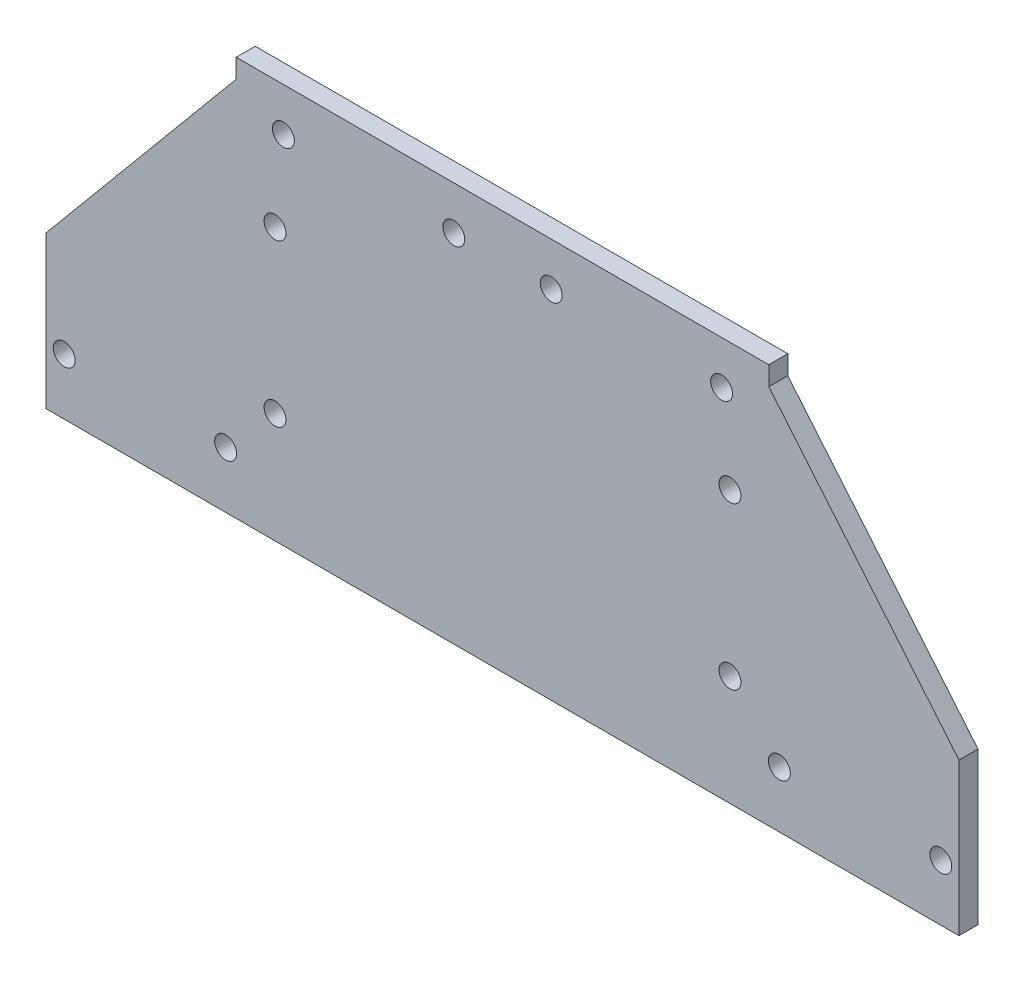
from build123d import *

# Parameters (mm, degrees)
SKETCH1_W           = 88.9
SKETCH1_H           = 3.175
BOSS_EXTRUDE1_DEPTH = 51.435
SKETCH2_R           = 1.8288
CUT_EXTRUDE1_DEPTH  = 4.175
SKETCH3_R           = 1.8288
CUT_EXTRUDE2_DEPTH  = 4.175
BOSS_EXTRUDE2_DEPTH = 3.175
CUT_EXTRUDE3_DEPTH  = 4.175
SKETCH6_R           = 1.8288
CUT_EXTRUDE4_DEPTH  = 4.175


with BuildPart() as part:
    # Sketch1 → Boss-Extrude1 (new body)
    with BuildSketch(Plane(origin=(0, 0, 0), x_dir=(1, 0, 0), z_dir=(0, 1, 0))):
        Rectangle(SKETCH1_W, SKETCH1_H)
    extrude(amount=BOSS_EXTRUDE1_DEPTH)

    # Sketch2 → Cut-Extrude1 (cut, through all)
    with BuildSketch(Plane.XY.offset(1.5875)):
        with Locations((-36.576, 44.196)):
            Circle(SKETCH2_R)
        with Locations((-8.128, 44.196)):
            Circle(SKETCH2_R)
        with Locations((8.128, 44.196)):
            Circle(SKETCH2_R)
        with Locations((36.576, 44.196)):
            Circle(SKETCH2_R)
    extrude(amount=-CUT_EXTRUDE1_DEPTH, mode=Mode.SUBTRACT)

    # Sketch3 → Cut-Extrude2 (cut, through all)
    with BuildSketch(Plane.XY.offset(1.5875)):
        with Locations((-37.973, 3.175)):
            Circle(SKETCH3_R)
        with Locations((-37.973, 30.1244)):
            Circle(SKETCH3_R)
        with Locations((37.973, 3.175)):
            Circle(SKETCH3_R)
        with Locations((37.973, 30.1244)):
            Circle(SKETCH3_R)
    extrude(amount=-CUT_EXTRUDE2_DEPTH, mode=Mode.SUBTRACT)

    # Sketch4 → Boss-Extrude2 (add)
    with BuildSketch(Plane.XY.offset(1.5875)):
        Polygon((-44.45, 0), (-44.45, 48.26), (-76.2, 48.26), (-76.2, 0), (-76.2, -15.24), (76.2, -15.24), (76.2, 0), (76.2, 48.26), (44.45, 48.26), (44.45, 0), (0, 0), align=None)
    extrude(amount=-BOSS_EXTRUDE2_DEPTH)

    # Sketch5 → Cut-Extrude3 (cut, through all)
    with BuildSketch(Plane.XY.offset(1.5875)):
        Polygon((-76.2, 10.16), (-44.45, 48.26), (-76.2, 48.26), align=None)
        Polygon((44.45, 48.26), (76.2, 10.16), (76.2, 48.26), align=None)
    extrude(amount=-CUT_EXTRUDE3_DEPTH, mode=Mode.SUBTRACT)

    # Sketch6 → Cut-Extrude4 (cut, through all)
    with BuildSketch(Plane.XY.offset(1.5875)):
        with Locations((-73.1647, -5.842)):
            Circle(SKETCH6_R)
        with Locations((-46.2153, -5.842)):
            Circle(SKETCH6_R)
        with Locations((46.2153, -5.842)):
            Circle(SKETCH6_R)
        with Locations((73.1647, -5.842)):
            Circle(SKETCH6_R)
    extrude(amount=-CUT_EXTRUDE4_DEPTH, mode=Mode.SUBTRACT)


solid = part.part
